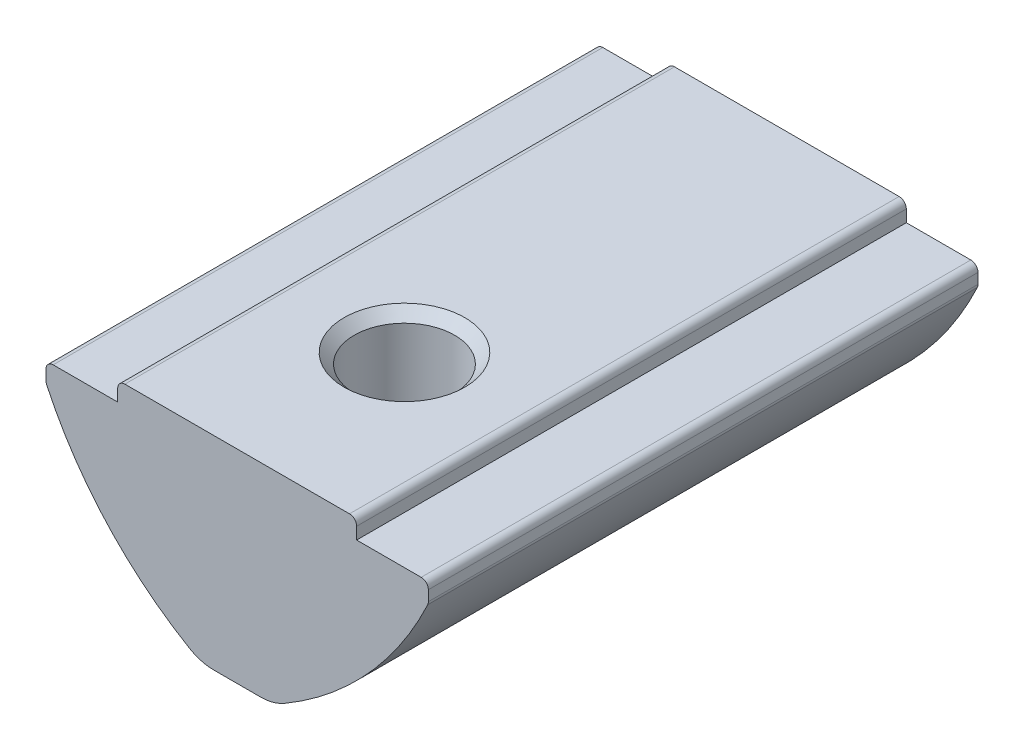
from build123d import *

# Parameters (mm, degrees)
EXTRUDE_1_DEPTH             = 11.5
FILLET_1_R                  = 0.3
FILLET_2_R                  = 2
HOLE_WIZARD_M53_D           = 4.2
HOLE_WIZARD_M53_CSINK_D     = 5.05
HOLE_WIZARD_M53_CSINK_ANGLE = 90


with BuildPart() as part:
    # Эскиз1 → Бобышка-Вытянуть1 (new body, symmetric)
    with BuildSketch(Plane.XY):
        with BuildLine():
            Line((-5, 0), (5, 0))
            Line((5, 0), (5, -0.8))
            Line((5, -0.8), (8, -0.8))
            Line((8, -0.8), (8, -1.6))
            ThreePointArc((8, -1.6), (5.309398779, -5.576969864), (1.5, -8.5))
            Line((1.5, -8.5), (-1.5, -8.5))
            ThreePointArc((-1.5, -8.5), (-5.309398779, -5.576969864), (-8, -1.6))
            Line((-8, -1.6), (-8, -0.8))
            Line((-8, -0.8), (-5, -0.8))
            Line((-5, -0.8), (-5, 0))
        make_face()
    extrude(amount=EXTRUDE_1_DEPTH, both=True)

    # Скругление1
    fillet_1_edges = [part.edges().sort_by_distance(p)[0] for p in [
        (8, -0.8, 0),
        (8, -1.6, 0),
        (-8, -1.6, 0),
        (-8, -0.8, 0),
        (-5, 0, 0),
        (5, 0, 0),
    ]]
    fillet(fillet_1_edges, radius=FILLET_1_R)

    # Скругление2
    fillet_2_edges = [part.edges().sort_by_distance(p)[0] for p in [
        (1.5, -8.5, 0),
        (-1.5, -8.5, 0),
    ]]
    fillet(fillet_2_edges, radius=FILLET_2_R)

    # Отверстие обработанное метчиком M53 (through all)
    with Locations(Plane(origin=(0, 0, 0), x_dir=(1, 0, 0), z_dir=(0, 1, 0))):
        with Locations((0, -4.5)):
            CounterSinkHole(HOLE_WIZARD_M53_D / 2, HOLE_WIZARD_M53_CSINK_D / 2, counter_sink_angle=HOLE_WIZARD_M53_CSINK_ANGLE)

    # Эскиз5 → Повернуть1 (revolve)
    with BuildSketch(Plane(origin=(0, 0, 0), x_dir=(0, 0, -1), z_dir=(1, 0, 0))):
        with BuildLine():
            Line((6.5, -4.3), (6.5, -9.3))
            ThreePointArc((6.5, -9.3), (4, -6.8), (6.5, -4.3))
        make_face()
    revolve(axis=Axis((0, -4.3, -6.5), (0, -1, 0)))


solid = part.part
